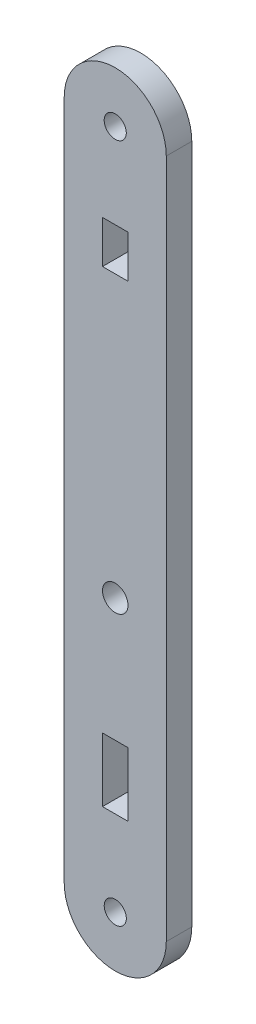
from build123d import *

# Parameters (mm, degrees)
MODEL_R             = 1.5
MODEL_R_2           = 1.3
MODEL_R_3           = 1.300000004
MODEL_W             = 3
MODEL_H             = 5
MODEL_H_2           = 7.5
BOSS_EXTRUDE1_DEPTH = 3


with BuildPart() as part:
    # Model → Boss-Extrude1 (new body)
    with BuildSketch(Plane.XY):
        with BuildLine():
            Line((49.143999996, 78.231573788), (49.143999996, -1.768426212))
            ThreePointArc((49.143999996, -1.768426212), (55.143949996, -7.768476212), (61.143999996, -1.768526212))
            Line((61.143999996, -1.768526212), (61.143999996, 78.231573788))
            ThreePointArc((61.143999996, 78.231573788), (55.143999996, 84.231573788), (49.143999996, 78.231573788))
        make_face()
        with Locations((55.144, 30.231473788)):
            Circle(MODEL_R, mode=Mode.SUBTRACT)
        with Locations((55.147158052, -1.761444485)):
            Circle(MODEL_R_2, mode=Mode.SUBTRACT)
        with Locations((55.143999996, 78.231573788)):
            Circle(MODEL_R_3, mode=Mode.SUBTRACT)
        with Locations((55.144, 65.731573788)):
            Rectangle(MODEL_W, MODEL_H, mode=Mode.SUBTRACT)
        with Locations((55.144, 11.981573788)):
            Rectangle(MODEL_W, MODEL_H_2, mode=Mode.SUBTRACT)
    extrude(amount=BOSS_EXTRUDE1_DEPTH)


solid = part.part
